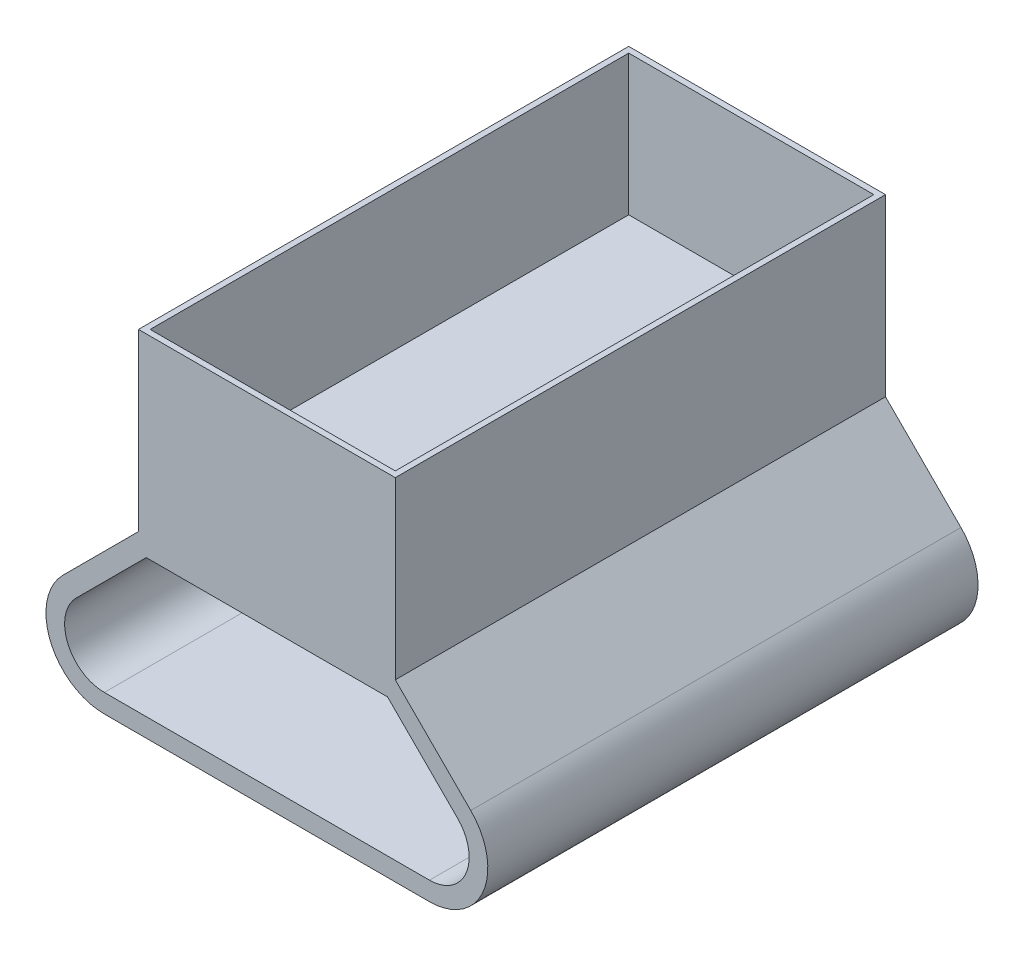
from build123d import *

# Parameters (mm, degrees)
BOSS_EXTRUDE1_DEPTH = 42
CUT_EXTRUDE1_DEPTH  = 49.448988367
SKETCH2_W           = 22
SKETCH2_H           = 42
SKETCH2_W_2         = 21
SKETCH2_H_2         = 41
BOSS_EXTRUDE2_DEPTH = 15
SKETCH2_2_W         = 21
SKETCH2_2_H         = 41
BOSS_EXTRUDE3_DEPTH = 3


with BuildPart() as part:
    # Sketch1 → Boss-Extrude1 (new body)
    with BuildSketch(Plane.XY):
        with BuildLine():
            Line((-11, 0), (11, 0))
            Line((11, 0), (17.464466094, -6.464466094))
            ThreePointArc((17.464466094, -6.464466094), (18.548329851, -11.913417162), (13.928932188, -15))
            Line((13.928932188, -15), (-13.928932188, -15))
            ThreePointArc((-13.928932188, -15), (-18.548329851, -11.913417162), (-17.464466094, -6.464466094))
            Line((-17.464466094, -6.464466094), (-11, 0))
        make_face()
    extrude(amount=BOSS_EXTRUDE1_DEPTH)

    # Sketch3 → Cut-Extrude1 (cut, through all)
    with BuildSketch(Plane.XY.offset(42)):
        with BuildLine():
            Line((-13.928932188, -13.4), (13.928932188, -13.4))
            ThreePointArc((13.928932188, -13.4), (17.070122599, -11.30112367), (16.333095244, -7.595836944))
            Line((16.333095244, -7.595836944), (10.3372583, -1.6))
            Line((10.3372583, -1.6), (-10.3372583, -1.6))
            Line((-10.3372583, -1.6), (-16.333095244, -7.595836944))
            ThreePointArc((-16.333095244, -7.595836944), (-17.070122599, -11.30112367), (-13.928932188, -13.4))
        make_face()
    extrude(amount=-CUT_EXTRUDE1_DEPTH, mode=Mode.SUBTRACT)

    # Sketch2 → Boss-Extrude2 (add)
    with BuildSketch(Plane(origin=(0, 0, 0), x_dir=(1, 0, 0), z_dir=(0, 1, 0))):
        with Locations((0, -21)):
            Rectangle(SKETCH2_W, SKETCH2_H)
        with Locations((0, -21)):
            Rectangle(SKETCH2_W_2, SKETCH2_H_2, mode=Mode.SUBTRACT)
    extrude(amount=BOSS_EXTRUDE2_DEPTH)

    # Sketch2_2 → Boss-Extrude3 (add)
    with BuildSketch(Plane(origin=(0, 0, 0), x_dir=(1, 0, 0), z_dir=(0, 1, 0))):
        with Locations((0, -21)):
            Rectangle(SKETCH2_2_W, SKETCH2_2_H)
    extrude(amount=BOSS_EXTRUDE3_DEPTH)


solid = part.part
